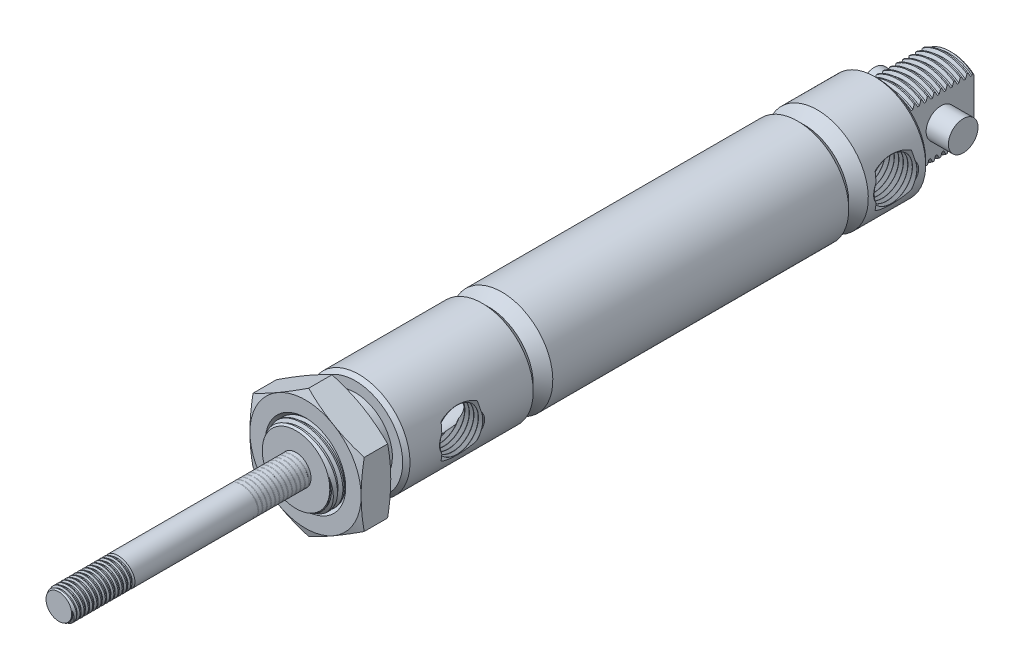
from build123d import *
from build123d.topology import SkipClean

# Parameters (mm, degrees)
SKETCH1_W            = 127.762
SKETCH1_H            = 10.922
SKETCH58_W           = 15.748
SKETCH58_H           = 2.9845
SKETCH59_OUTSIDE_W   = 50.132
SKETCH59_OUTSIDE_H   = 50.132
SKETCH59_OUTSIDE_W_2 = 9.525
SKETCH59_OUTSIDE_H_2 = 15.875
CUT_EXTRUDE3_DEPTH   = 15.748
CHAMFER1_SIZE        = 0.7874
SKETCH4_W            = 12.7
SKETCH4_H            = 7.9375
LPATTERN2_COUNT      = 2
LPATTERN2_PITCH      = 1.411111224
LPATTERN2_COL_COUNT  = 9
LPATTERN2_COL_PITCH  = 1.411111224
SKETCH53_W           = 2.286
SKETCH53_H           = 7.9375
LPATTERN5_COUNT      = 11
LPATTERN5_PITCH      = 1.411111224
SKETCH60_R           = 3.175
EXTRUDE2_DEPTH       = 9.525
LPATTERN3_COUNT      = 2
LPATTERN3_PITCH      = 0.907142966
LPATTERN3_COL_COUNT  = 14
LPATTERN3_COL_PITCH  = 0.907142966
LPATTERN4_COUNT      = 2
LPATTERN4_PITCH      = 38.1
SKETCH54_R           = 7.9375
EXTRUDE1_DEPTH       = 3.175


with BuildPart() as part:
    # Sketch1 → Revolve1 (revolve)
    with BuildSketch(Plane(origin=(0, 0, 0), x_dir=(0, 0, -1), z_dir=(1, 0, 0)), mode=Mode.PRIVATE) as revolve1_sk:
        with Locations((12.7, 5.461)):
            Rectangle(SKETCH1_W, SKETCH1_H)
    revolve(revolve1_sk.sketch.rotate(Axis((0, 0, -76.581), (0, 0, -1)), 270), axis=Axis((0, 0, -76.581), (0, 0, -1)))

    # Sketch58 → Cut-Revolve25 (revolve, cut)
    with BuildSketch(Plane(origin=(0, 0, 0), x_dir=(0, 0, -1), z_dir=(1, 0, 0)), mode=Mode.PRIVATE) as cut_revolve25_sk:
        with Locations((68.707, 9.42975)):
            Rectangle(SKETCH58_W, SKETCH58_H)
    revolve(cut_revolve25_sk.sketch.rotate(Axis((0, 0, -76.581), (0, 0, -1)), 270), axis=Axis((0, 0, -76.581), (0, 0, -1)), mode=Mode.SUBTRACT)

    # Sketch59 outside → Cut-Extrude3 (cut)
    with BuildSketch(Plane(origin=(0, 0, -76.581), x_dir=(-1, 0, 0), z_dir=(0, 0, -1))):
        Rectangle(SKETCH59_OUTSIDE_W, SKETCH59_OUTSIDE_H)
        Rectangle(SKETCH59_OUTSIDE_W_2, SKETCH59_OUTSIDE_H_2, mode=Mode.SUBTRACT)
    extrude(amount=-CUT_EXTRUDE3_DEPTH, mode=Mode.SUBTRACT)

    # Chamfer1
    chamfer1_edges = [part.edges().sort_by_distance(p)[0] for p in [
        (0, -7.9375, -76.581),
        (10.922, 0, 51.181),
        (10.922, 0, -60.833),
        (0, 7.9375, -76.581),
    ]]
    chamfer(chamfer1_edges, length=CHAMFER1_SIZE)



with BuildPart() as body_2:
    # Sketch4 → Revolve2 (revolve)
    with BuildSketch(Plane(origin=(0, 0, 0), x_dir=(0, 0, -1), z_dir=(1, 0, 0)), mode=Mode.PRIVATE) as revolve2_sk:
        with Locations((-57.531, 3.96875)):
            Rectangle(SKETCH4_W, SKETCH4_H)
    revolve(revolve2_sk.sketch.rotate(Axis((0, 0, 63.881), (0, 0, -1)), 90), axis=Axis((0, 0, 63.881), (0, 0, -1)))

    # Sketch5 → Cut-Revolve2 (revolve, cut)
    with BuildSketch(Plane(origin=(0, 0, 0), x_dir=(0, 0, -1), z_dir=(1, 0, 0)), mode=Mode.PRIVATE) as cut_revolve2_sk:
        Polygon((-63.70530384, 7.953117438), (-62.475430718, 8.062439502), (-62.847045629, 7.262609217), (-63.19843795, 7.231374341), align=None)
    cut_revolve2 = revolve(cut_revolve2_sk.sketch.rotate(Axis((0, -0.133549816, 63.881), (0, 0.08853979731145087, -0.996072640068006)), 180), axis=Axis((0, -0.133549816, 63.881), (0, 0.08853979731145087, -0.996072640068006)), mode=Mode.SUBTRACT)

    # Sketch6 → Cut-Revolve3 (revolve, cut)
    with BuildSketch(Plane(origin=(0, 0, 0), x_dir=(0, 0, -1), z_dir=(1, 0, 0)), mode=Mode.PRIVATE) as cut_revolve3_sk:
        Polygon((-63.881, 7.231374341), (-62.657954482, 7.9375), (-63.881, 7.9375), align=None)
    revolve(cut_revolve3_sk.sketch.rotate(Axis((0, 0, 0), (0, 0, 1)), 270), axis=Axis((0, 0, 0), (0, 0, 1)), mode=Mode.SUBTRACT)

    # LPattern2: Cut-Revolve2 ×2
    with Locations(*[(0, 0, i * LPATTERN2_PITCH) for i in range(1, LPATTERN2_COUNT)]):
        add(cut_revolve2, mode=Mode.SUBTRACT)

    # LPattern2 col: Cut-Revolve2 ×9
    with Locations(*[(0, 0, -i * LPATTERN2_COL_PITCH) for i in range(1, LPATTERN2_COL_COUNT)]):
        add(cut_revolve2, mode=Mode.SUBTRACT)


with BuildPart() as part_1:
    with SkipClean():  # the faces are left unmerged after this step: merging them gives an invalid solid
        add(part.part)

        add(body_2.part)  # Revolve4 merges body 2
        # Sketch53 → Revolve4 (revolve)
        with BuildSketch(Plane(origin=(0, 0, 0), x_dir=(0, 0, -1), z_dir=(1, 0, 0)), mode=Mode.PRIVATE) as revolve4_sk:
            with Locations((-52.324, 3.96875)):
                Rectangle(SKETCH53_W, SKETCH53_H)
        revolve(revolve4_sk.sketch.rotate(Axis((0, 0, 51.181), (0, 0, 1)), 125.383849969), axis=Axis((0, 0, 51.181), (0, 0, 1)))

    # Sketch62 → Cut-Revolve26 (revolve, cut)
    with SkipClean():  # the faces are left unmerged after this step: merging them gives an invalid solid
        with BuildSketch(Plane(origin=(0, 0, 0), x_dir=(0, 0, -1), z_dir=(1, 0, 0))):
            Polygon((61.00869616, 7.953117438), (62.238569282, 8.062439502), (61.866954371, 7.262609217), (61.51556205, 7.231374341), align=None)
        cut_revolve26 = revolve(axis=Axis((0, -0.133549816, -60.833), (0, 0.08853979731145116, -0.9960726400680059)), mode=Mode.SUBTRACT)

    # LPattern5: Cut-Revolve26 ×11
    with SkipClean():  # the faces are left unmerged after this step: merging them gives an invalid solid
        with Locations(*[(0, 0, -i * LPATTERN5_PITCH) for i in range(1, LPATTERN5_COUNT)]):
            add(cut_revolve26, mode=Mode.SUBTRACT)

    # Sketch60 → Extrude2 (add, symmetric)
    with SkipClean():  # the faces are left unmerged after this step: merging them gives an invalid solid
        with BuildSketch(Plane(origin=(0, 0, 0), x_dir=(0, 0, -1), z_dir=(1, 0, 0))):
            with Locations(Location((69.469, 0, 0), (0, 0, 180))):
                Circle(SKETCH60_R)
        extrude(amount=EXTRUDE2_DEPTH, both=True)

    # Sketch7 → Cut-Revolve5 (revolve, cut)
    with SkipClean():  # the faces are left unmerged after this step: merging them gives an invalid solid
        with BuildSketch(Plane(origin=(0, 0, 0), x_dir=(0, 0, -1), z_dir=(1, 0, 0)), mode=Mode.PRIVATE) as cut_revolve5_sk:
            Polygon((-63.881, 3.2004), (-48.006, 3.2004), (-48.006, 6.3627), (-5.842, 6.3627), (-5.842, 9.525), (0.508, 9.525), (38.608, 9.525), (38.608, 0), (-63.881, 0), align=None)
            Polygon((43.561, 10.922), (44.958, 9.525), (44.958, 8.128), (47.752, 10.922), align=None)
            Polygon((-24.003, 10.922), (-22.606, 9.525), (-22.606, 8.128), (-19.812, 10.922), align=None)
        revolve(cut_revolve5_sk.sketch.rotate(Axis((0, 0, -38.608), (0, 0, -1)), 180), axis=Axis((0, 0, -38.608), (0, 0, -1)), mode=Mode.SUBTRACT)

    # Sketch13 → Cut-Revolve22 (revolve, cut)
    with SkipClean():  # the faces are left unmerged after this step: merging them gives an invalid solid
        with BuildSketch(Plane(origin=(-356.431898312, -1.751719437, -53.721), x_dir=(1, 0, 0), z_dir=(0, 0, 1))):
            Polygon((355.923898312, 1.751719437), (355.923898312, 5.954267841), (355.940851644, 5.985872426), (356.351637466, 6.751663784), (356.387484506, 6.75278406), (356.845286365, 6.014137423), (356.881133404, 6.015257699), (357.291919226, 6.781049057), (357.327766266, 6.782169333), (357.785568125, 6.043522697), (357.821415164, 6.044642973), (358.232200986, 6.810434331), (358.268048026, 6.811554607), (358.725849885, 6.07290797), (358.761696925, 6.074028246), (359.172482747, 6.839819604), (359.208329786, 6.84093988), (359.666131645, 6.102293244), (359.701978685, 6.10341352), (360.112764507, 6.869204878), (360.148611546, 6.870325154), (360.606413405, 6.131678517), (360.642260445, 6.132798793), (361.053046267, 6.898590151), (361.088893307, 6.899710427), (361.546695166, 6.161063791), (361.582542205, 6.162184066), (361.993328027, 6.927975424), (362.029175067, 6.9290957), (362.486976926, 6.190449064), (362.522823965, 6.19156934), (362.933609788, 6.957360698), (362.969456827, 6.958480974), (363.427258686, 6.219834337), (363.463105726, 6.220954613), (363.873891548, 6.986745971), (363.909738587, 6.987866247), (364.367540446, 6.249219611), (364.403387486, 6.250339887), (364.814173308, 7.016131245), (364.850020348, 7.017251521), (365.307822206, 6.278604884), (365.343669246, 6.27972516), (365.754455068, 7.045516518), (365.790302108, 7.046636794), (366.248103967, 6.307990158), (366.283951006, 6.309110434), (366.694736828, 7.074901792), (366.730583868, 7.076022068), (367.188385727, 6.337375431), (367.224232766, 6.338495707), (367.635018589, 7.104287065), (367.670865628, 7.105407341), (368.128667487, 6.366760705), (368.164514527, 6.367880981), (368.575300349, 7.133672339), (368.611147388, 7.134792615), (369.068949247, 6.396145978), (369.104796287, 6.397266254), (369.515582109, 7.163057612), (369.551429149, 7.164177888), (370.009231008, 6.425531252), (370.045078047, 6.426651528), (370.045078047, 1.751719437), align=None)
        revolve(axis=Axis((-0.508, 0, -53.721), (-1, 0, 0)), mode=Mode.SUBTRACT)

    # Sketch64 → Cut-Revolve27 (revolve, cut)
    with SkipClean():  # the faces are left unmerged after this step: merging them gives an invalid solid
        with BuildSketch(Plane(origin=(-356.431898312, -1.751719437, 39.243), x_dir=(1, 0, 0), z_dir=(0, 0, 1)), mode=Mode.PRIVATE) as cut_revolve27_sk:
            Polygon((355.923898312, 1.751719437), (355.923898312, 5.954267873), (355.949328308, 6.001674747), (356.343160766, 6.735861461), (356.396931321, 6.737541875), (356.835839438, 6.029379604), (356.889609993, 6.031060018), (357.283442451, 6.765246732), (357.337213006, 6.766927146), (357.776121123, 6.058764875), (357.829891678, 6.060445289), (358.223724136, 6.794632004), (358.277494691, 6.796312417), (358.716402808, 6.088150147), (358.770173363, 6.08983056), (359.164005821, 6.824017275), (359.217776376, 6.825697688), (359.656684493, 6.117535418), (359.710455048, 6.119215831), (360.104287506, 6.853402546), (360.158058061, 6.85508296), (360.596966178, 6.146920689), (360.650736733, 6.148601103), (361.044569191, 6.882787817), (361.098339746, 6.884468231), (361.537247863, 6.17630596), (361.591018418, 6.177986374), (361.984850876, 6.912173088), (362.038621431, 6.913853502), (362.477529548, 6.205691231), (362.531300103, 6.207371645), (362.925132561, 6.941558359), (362.978903116, 6.943238773), (363.417811233, 6.235076502), (363.471581788, 6.236756916), (363.865414246, 6.97094363), (363.919184801, 6.972624044), (364.358092918, 6.264461773), (364.411863473, 6.266142187), (364.805695931, 7.000328901), (364.859466486, 7.002009315), (365.298374603, 6.293847044), (365.352145158, 6.295527458), (365.745977616, 7.029714172), (365.799748171, 7.031394586), (366.238656288, 6.323232315), (366.292426843, 6.324912729), (366.686259301, 7.059099443), (366.740029856, 7.060779857), (367.178937973, 6.352617586), (367.232708528, 6.354298), (367.626540986, 7.088484715), (367.680311541, 7.090165128), (368.119219658, 6.382002857), (368.172990213, 6.383683271), (368.566822671, 7.117869986), (368.620593226, 7.119550399), (369.059501343, 6.411388129), (369.113271898, 6.413068542), (369.507104356, 7.147255257), (369.560874911, 7.148935671), (369.999783028, 6.4407734), (370.053553583, 6.442453814), (370.053553583, 1.751719437), align=None)
        revolve(cut_revolve27_sk.sketch.rotate(Axis((-0.508, 0, 39.243), (1, 0, 0)), 90), axis=Axis((-0.508, 0, 39.243), (1, 0, 0)), mode=Mode.SUBTRACT)


with BuildPart() as body_2_2:
    # Sketch8 → Revolve3 (revolve)
    with BuildSketch(Plane(origin=(0, 0, 0), x_dir=(0, 0, -1), z_dir=(1, 0, 0)), mode=Mode.PRIVATE) as revolve3_sk:
        Polygon((32.258, 9.4742), (38.608, 9.4742), (38.608, 0), (-76.581, 0), (-76.581, 3.175), (32.258, 3.175), align=None)
    revolve(revolve3_sk.sketch.rotate(Axis((0, 0, -38.608), (0, 0, 1)), 125.383849969), axis=Axis((0, 0, -38.608), (0, 0, 1)))

    # Sketch10 → Cut-Revolve6 (revolve, cut)
    with BuildSketch(Plane(origin=(0, 0, 0), x_dir=(0, 0, -1), z_dir=(1, 0, 0)), mode=Mode.PRIVATE) as cut_revolve6_sk:
        Polygon((-76.468746785, 3.191036175), (-75.682974282, 3.303289404), (-75.894168642, 2.777128287), (-76.118675072, 2.745055936), align=None)
    cut_revolve6 = revolve(cut_revolve6_sk.sketch.rotate(Axis((0, -0.138431434, 76.581), (0, 0.14142137286846057, -0.9899494912852878)), 180), axis=Axis((0, -0.138431434, 76.581), (0, 0.14142137286846057, -0.9899494912852878)), mode=Mode.SUBTRACT)

    # Sketch11 → Cut-Revolve7 (revolve, cut)
    with BuildSketch(Plane(origin=(0, 0, 0), x_dir=(0, 0, -1), z_dir=(1, 0, 0)), mode=Mode.PRIVATE) as cut_revolve7_sk:
        Polygon((-76.581, 3.175), (-75.836315037, 3.175), (-76.581, 2.745055936), align=None)
    revolve(cut_revolve7_sk.sketch.rotate(Axis((0, 0, 0), (0, 0, 1)), 125.383849969), axis=Axis((0, 0, 0), (0, 0, 1)), mode=Mode.SUBTRACT)

    # LPattern3: Cut-Revolve6 ×2
    with Locations(*[(0, 0, i * LPATTERN3_PITCH) for i in range(1, LPATTERN3_COUNT)]):
        add(cut_revolve6, mode=Mode.SUBTRACT)

    # LPattern3 col: Cut-Revolve6 ×14
    with Locations(*[(0, 0, -i * LPATTERN3_COL_PITCH) for i in range(1, LPATTERN3_COL_COUNT)]):
        add(cut_revolve6, mode=Mode.SUBTRACT)


with BuildPart() as lpattern4_1:
    # LPattern4: pattern copy
    add(body_2_2.part.moved(Location(Vector(0, 0, 1) * (1 * LPATTERN4_PITCH))))


with BuildPart() as body_4:
    # Sketch54 → Extrude1 (new, symmetric)
    with BuildSketch(Plane.XY.offset(58.674)):
        Polygon((0, 13.748153285), (-11.90625, 6.874076643), (-11.90625, -6.874076643), (0, -13.748153285), (11.90625, -6.874076643), (11.90625, 6.874076643), align=None)
        Circle(SKETCH54_R, mode=Mode.SUBTRACT)
    extrude(amount=EXTRUDE1_DEPTH, both=True)

    # Sketch55 → Cut-Revolve24 (revolve, cut)
    with BuildSketch(Plane(origin=(0, 0, 0), x_dir=(0, 0, -1), z_dir=(1, 0, 0)), mode=Mode.PRIVATE) as cut_revolve24_sk:
        Polygon((-61.17860203, 13.748153285), (-61.849, 13.748153285), (-61.849, 11.90625), align=None)
        Polygon((-56.16939797, 13.748153285), (-55.499, 13.748153285), (-55.499, 11.90625), align=None)
        Polygon((-61.849, 8.60789797), (-61.849, 7.9375), (-61.17860203, 7.9375), align=None)
        Polygon((-55.499, 8.60789797), (-55.499, 7.9375), (-56.16939797, 7.9375), align=None)
    revolve(cut_revolve24_sk.sketch.rotate(Axis((0, 0, 0), (0, 0, 1)), 124.802032131), axis=Axis((0, 0, 0), (0, 0, 1)), mode=Mode.SUBTRACT)


solid = Compound([part_1.part, body_2_2.part, lpattern4_1.part, body_4.part])
